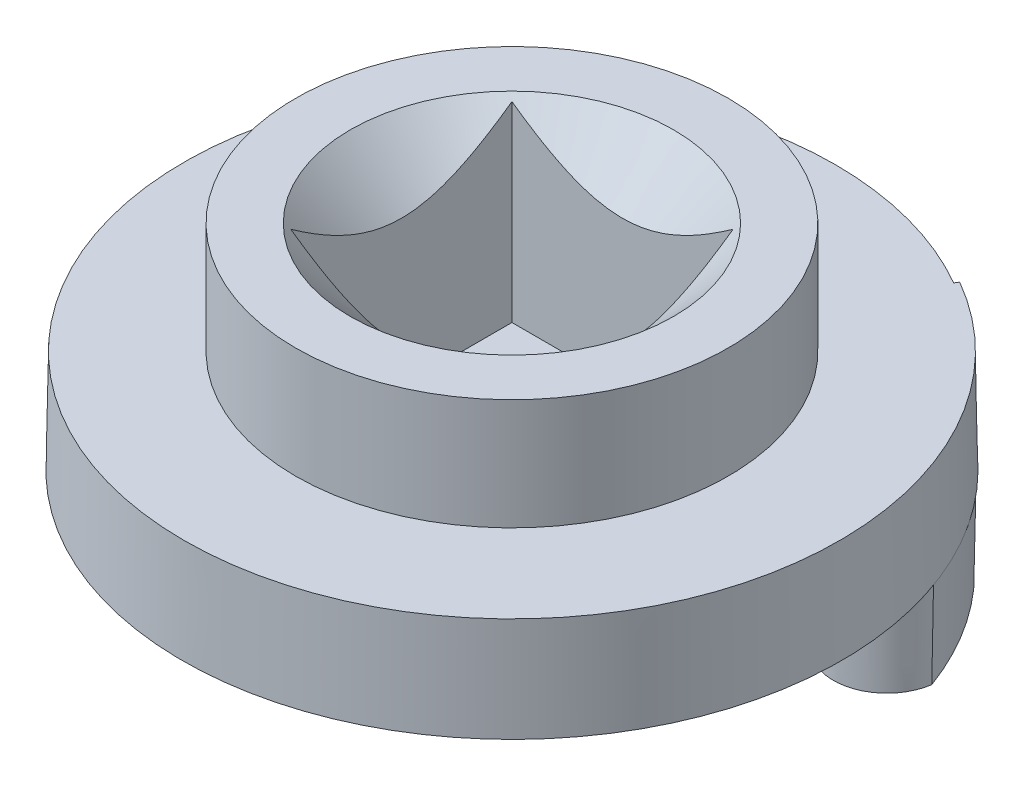
from build123d import *

# Parameters (mm, degrees)
SKETCH2_W           = 6.4262
SKETCH2_H           = 6.4262
CUT_EXTRUDE1_DEPTH  = 6.715
DRAFT1_ANGLE        = 1
BOSS_EXTRUDE2_DEPTH = 2.54
BOSS_EXTRUDE2_TAPER = 1
BOSS_EXTRUDE3_DEPTH = 0.508
BOSS_EXTRUDE3_TAPER = 1
CUT_EXTRUDE2_DEPTH  = 6.5372
CUT_EXTRUDE2_TAPER  = 1


with BuildPart() as part:
    # Sketch1 → Revolve1 (revolve)
    with BuildSketch(Plane.XY):
        Polygon((0, 0), (9.525, 0), (9.525, 2.9972), (6.2865, 2.9972), (6.2865, 6.223), (0, 6.223), align=None)
    revolve(axis=Axis((0, -4.12115, 0), (0, 1, 0)))

    # Sketch2 → Cut-Extrude1 (cut, through all)
    with BuildSketch(Plane(origin=(0, 0.508, 0), x_dir=(1, 0, 0), z_dir=(0, 1, 0))):
        Rectangle(SKETCH2_W, SKETCH2_H)
    extrude(amount=CUT_EXTRUDE1_DEPTH, mode=Mode.SUBTRACT)

    # Sketch3 → Cut-Revolve1 (revolve, cut)
    with BuildSketch(Plane.XY):
        Polygon((0, 6.223), (4.699, 6.223), (0, 1.524), align=None)
    revolve(axis=Axis((0, 0, 0), (0, 1, 0)), mode=Mode.SUBTRACT)

    # Draft1
    draft1_faces = [part.faces().sort_by_distance(p)[0] for p in [
        (-9.525, 1.4986, 0),
    ]]
    draft(draft1_faces, Plane(origin=(9.525, 2.9972, 0), x_dir=(0, 0, 1), z_dir=(0, 1, 0)), DRAFT1_ANGLE)

    # Sketch4 → Boss-Extrude2 (add)
    with BuildSketch(Plane.XZ):
        with BuildLine():
            ThreePointArc((5.337752, -3.855992), (5.351306, -5.763469), (7.181023, -6.302716))
            ThreePointArc((7.181023, -6.302716), (8.233547, -4.861812), (9.000511, -3.250672))
            ThreePointArc((9.000511, -3.250672), (7.655973, -1.897575), (5.971572, -2.792809))
            ThreePointArc((5.971572, -2.792809), (5.679626, -3.339283), (5.337752, -3.855992))
        make_face()
    extrude(amount=BOSS_EXTRUDE2_DEPTH, taper=BOSS_EXTRUDE2_TAPER)

    # Sketch5 → Boss-Extrude3 (add)
    with BuildSketch(Plane.XZ):
        with BuildLine():
            Line((-6.159337, 5.690783), (-7.058911, 6.472771))
            ThreePointArc((-7.058911, 6.472771), (-7.228092, 6.283285), (-7.392189, 6.089379))
            Line((-7.392189, 6.089379), (-6.492615, 5.307391))
            Line((-6.492615, 5.307391), (-6.159337, 5.690783))
        make_face()
    extrude(amount=BOSS_EXTRUDE3_DEPTH, taper=BOSS_EXTRUDE3_TAPER)

    # Sketch6 → Cut-Extrude2 (cut, through all)
    with BuildSketch(Plane(origin=(0, 2.9972, 0), x_dir=(1, 0, 0), z_dir=(0, 1, 0))):
        with BuildLine():
            Line((-5.08, 8.798818), (-4.699, 8.138907))
            ThreePointArc((-4.699, 8.138907), (0, 9.398), (4.699, 8.138907))
            Line((4.699, 8.138907), (5.08, 8.798818))
            ThreePointArc((5.08, 8.798818), (0, 10.16), (-5.08, 8.798818))
        make_face()
    extrude(amount=-CUT_EXTRUDE2_DEPTH, taper=CUT_EXTRUDE2_TAPER, mode=Mode.SUBTRACT)


solid = part.part
